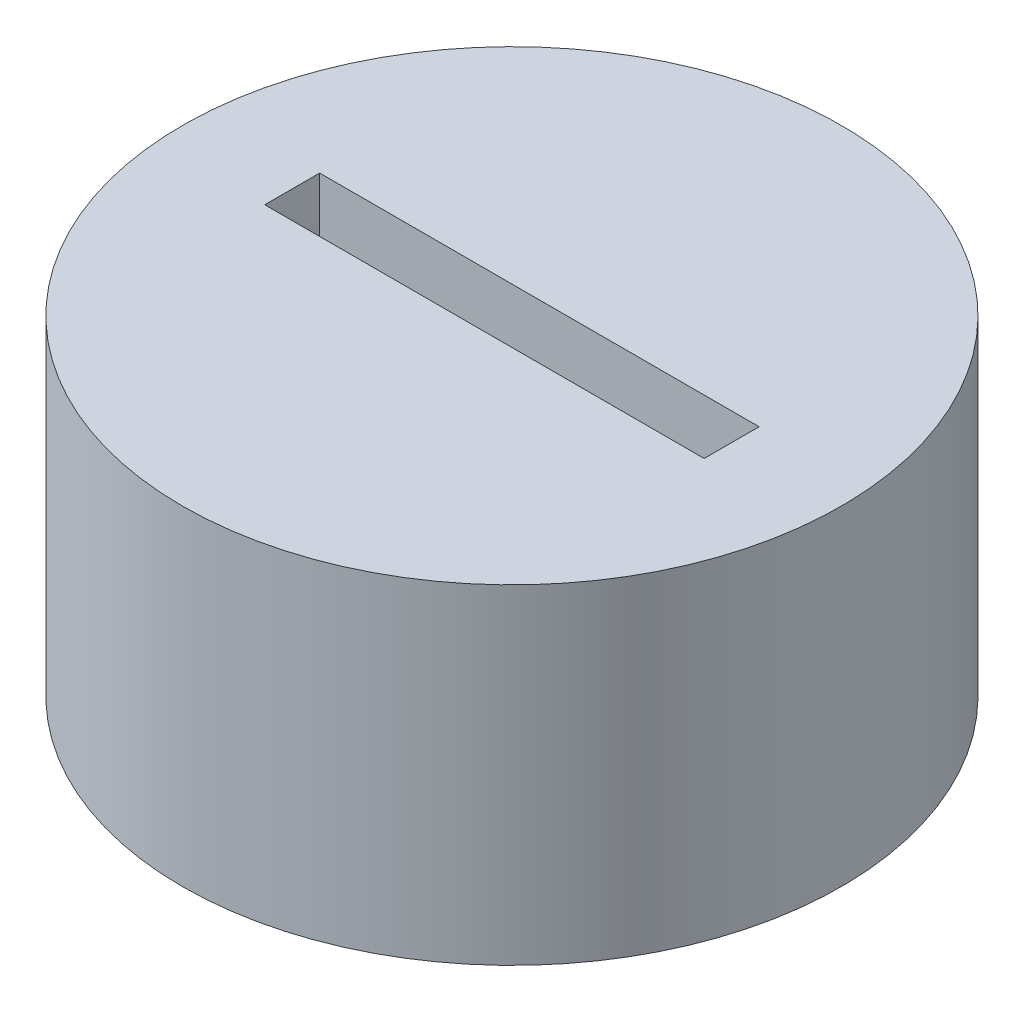
from build123d import *

# Parameters (mm, degrees)
SKIZZE1_R                       = 6
AUFSATZ_LINEAR_AUSTRAGEN1_DEPTH = 6
SKIZZE2_W                       = 8
SKIZZE2_H                       = 1
SCHNITT_LINEAR_AUSTRAGEN1_DEPTH = 1.5
SKIZZE3_W                       = 1
SKIZZE3_H                       = 8
SCHNITT_LINEAR_AUSTRAGEN2_DEPTH = 1.5


with BuildPart() as part:
    # Skizze1 → Aufsatz-Linear austragen1 (new body)
    with BuildSketch(Plane(origin=(0, 0, 0), x_dir=(1, 0, 0), z_dir=(0, 1, 0))):
        Circle(SKIZZE1_R)
    extrude(amount=AUFSATZ_LINEAR_AUSTRAGEN1_DEPTH)

    # Skizze2 → Schnitt-Linear austragen1 (cut)
    with BuildSketch(Plane(origin=(0, 6, 0), x_dir=(1, 0, 0), z_dir=(0, 1, 0))):
        Rectangle(SKIZZE2_W, SKIZZE2_H)
    extrude(amount=-SCHNITT_LINEAR_AUSTRAGEN1_DEPTH, mode=Mode.SUBTRACT)

    # Skizze3 → Schnitt-Linear austragen2 (cut)
    with BuildSketch(Plane.XZ):
        Rectangle(SKIZZE3_W, SKIZZE3_H)
    extrude(amount=-SCHNITT_LINEAR_AUSTRAGEN2_DEPTH, mode=Mode.SUBTRACT)


solid = part.part
